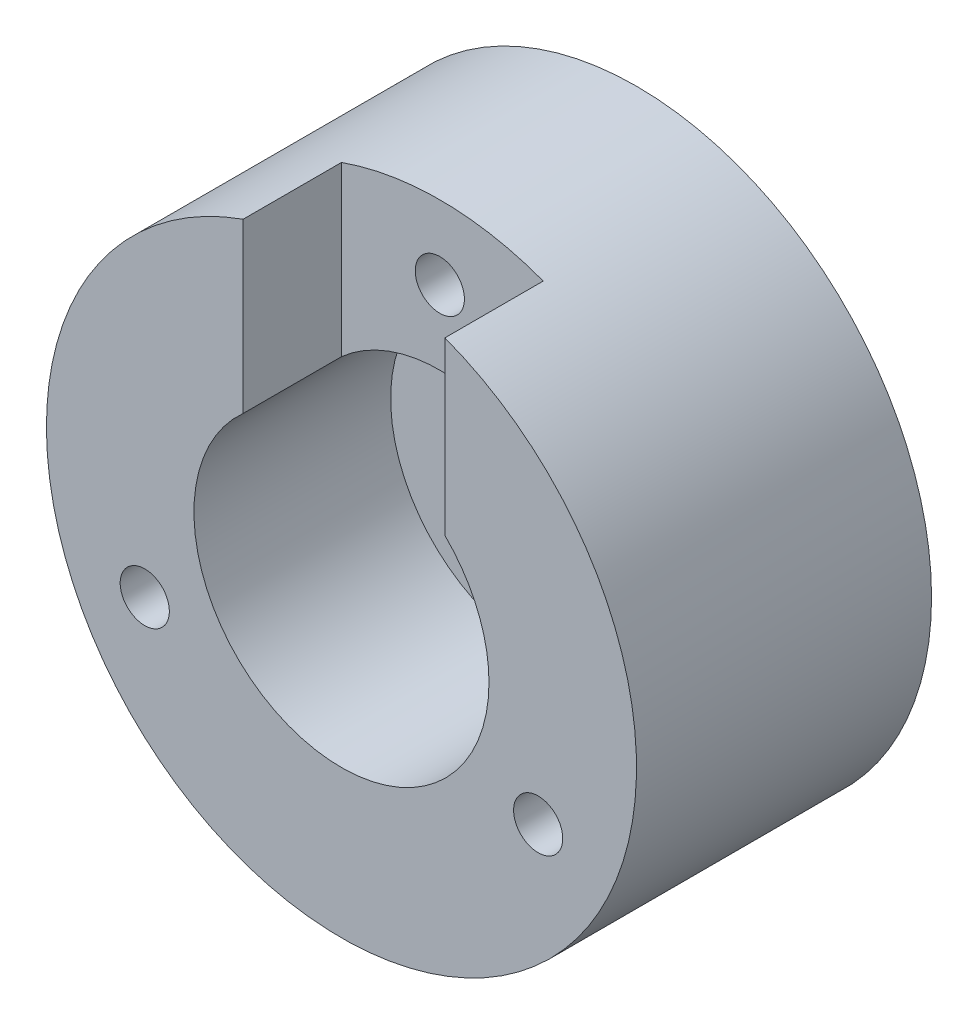
from build123d import *

# Parameters (mm, degrees)
SKETCH1_R           = 60
BOSS_EXTRUDE1_DEPTH = 60
SKETCH2_R           = 30
CUT_EXTRUDE1_DEPTH  = 40
SKETCH3_R           = 10
CUT_EXTRUDE2_DEPTH  = 40
SKETCH4_R           = 5
CUT_EXTRUDE3_DEPTH  = 100
SKETCH5_R           = 5
CUT_EXTRUDE4_DEPTH  = 100
CUT_EXTRUDE5_DEPTH  = 20


with BuildPart() as part:
    # Sketch1 → Boss-Extrude1 (new body)
    with BuildSketch(Plane.XY):
        Circle(SKETCH1_R)
    extrude(amount=BOSS_EXTRUDE1_DEPTH)

    # Sketch2 → Cut-Extrude1 (cut)
    with BuildSketch(Plane.XY.offset(60)):
        Circle(SKETCH2_R)
    extrude(amount=-CUT_EXTRUDE1_DEPTH, mode=Mode.SUBTRACT)

    # Sketch3 → Cut-Extrude2 (cut)
    with BuildSketch(Plane.XY.offset(20)):
        Circle(SKETCH3_R)
    extrude(amount=-CUT_EXTRUDE2_DEPTH, mode=Mode.SUBTRACT)

    # Sketch4 → Cut-Extrude3 (cut)
    with BuildSketch(Plane.XY.offset(60)):
        with Locations((0, 45)):
            Circle(SKETCH4_R)
    extrude(amount=-CUT_EXTRUDE3_DEPTH, mode=Mode.SUBTRACT)

    # Sketch5 → Cut-Extrude4 (cut)
    with BuildSketch(Plane.XY.offset(60)):
        with Locations((-40, -20)):
            Circle(SKETCH5_R)
        with Locations((40, -20)):
            Circle(SKETCH5_R)
    extrude(amount=-CUT_EXTRUDE4_DEPTH, mode=Mode.SUBTRACT)

    # Sketch6 → Cut-Extrude5 (cut)
    with BuildSketch(Plane.XY.offset(60)):
        with BuildLine():
            Line((-20, 56.568542495), (-20, 22.360679775))
            ThreePointArc((-20, 22.360679775), (0.705121947, 29.991712239), (21.02874571, 21.396070991))
            Line((21.02874571, 21.396070991), (21.02874571, 56.194233279))
            ThreePointArc((21.02874571, 56.194233279), (0.547363025, 59.997503229), (-20, 56.568542495))
        make_face()
    extrude(amount=-CUT_EXTRUDE5_DEPTH, mode=Mode.SUBTRACT)


solid = part.part
